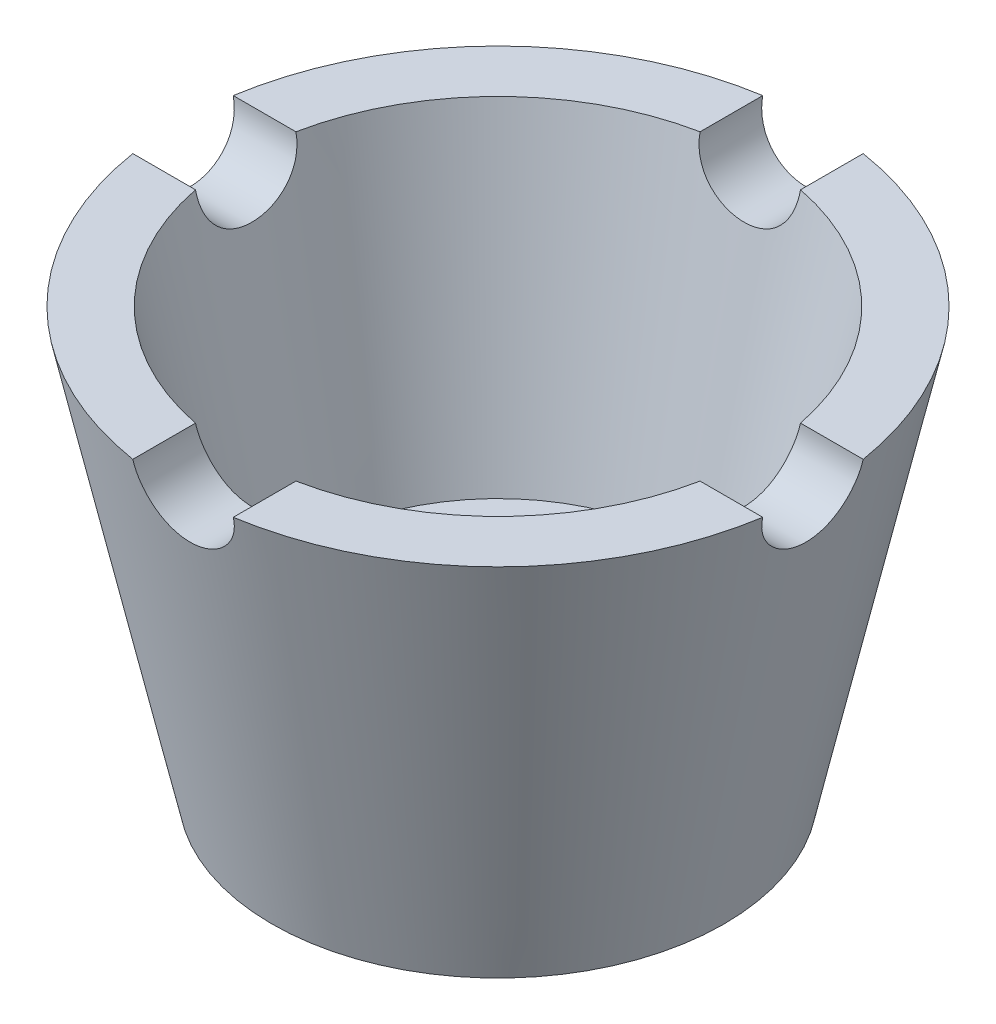
from build123d import *

# Parameters (mm, degrees)
SKETCH2_R          = 5
CUT_EXTRUDE1_DEPTH = 35.5
CIRPATTERN1_COUNT  = 4


with BuildPart() as part:
    # Sketch1 → Revolve1 (revolve)
    with BuildSketch(Plane.XY):
        Polygon((11.880841121, 0), (22.5, 0), (31.753664233, 42), (25.609760166, 42), (19, 12), (11, 12), (11, 0), align=None)
    revolve(axis=Axis((0, 0, 0), (0, 1, 0)))

    # Sketch2 → Cut-Extrude1 (cut, symmetric)
    with BuildSketch(Plane.XY):
        with Locations((0, 42)):
            Circle(SKETCH2_R)
    cut_extrude1 = extrude(amount=CUT_EXTRUDE1_DEPTH, both=True, mode=Mode.SUBTRACT)

    # CirPattern1: Cut-Extrude1 ×4 about axis
    cirpattern1_axis = Axis((0, 0, 0), (0, 1, 0))
    for i in range(1, CIRPATTERN1_COUNT):
        add(cut_extrude1.rotate(cirpattern1_axis, i * 360 / CIRPATTERN1_COUNT), mode=Mode.SUBTRACT)


solid = part.part
